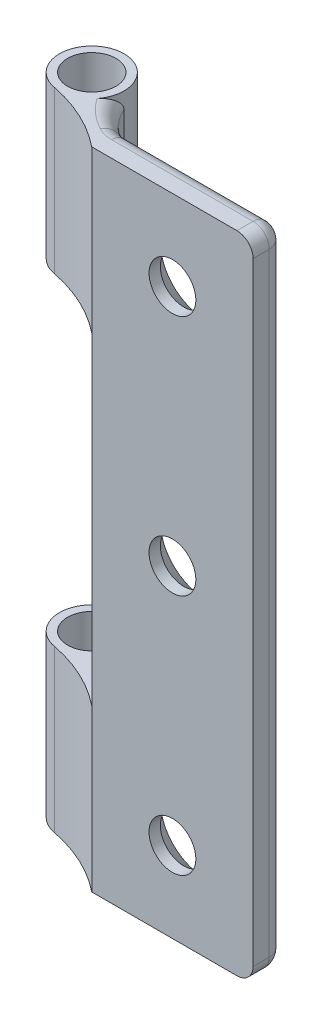
from build123d import *

# Parameters (mm, degrees)
SKETCH3_R                                    = 1.5
BOSS_EXTRUDE2_DEPTH                          = 40
SKETCH4_W                                    = 6
SKETCH4_H                                    = 20
CUT_EXTRUDE1_DEPTH                           = 40
CUT_EXTRUDE1_DEPTH_BACK                      = 200
FILLET1_R                                    = 1
FILLET2_R                                    = 1
CSK_FOR_M2_5_COUNTERSUNK_FLAT_HEAD_S_2_COUNT = 2
CSK_FOR_M2_5_COUNTERSUNK_FLAT_HEAD_S_2_PITCH = 15
CSK_FOR_M2_5_COUNTERSUNK_FLAT_HEAD_S_3_COUNT = 2
CSK_FOR_M2_5_COUNTERSUNK_FLAT_HEAD_S_3_PITCH = 30


with BuildPart() as part:
    # Sketch3 → Boss-Extrude2 (new body)
    with BuildSketch(Plane(origin=(0, 0, 0), x_dir=(1, 0, 0), z_dir=(0, 1, 0))):
        with BuildLine():
            Line((-5, 1), (5, 1))
            Line((5, 1), (5, -1))
            Line((5, -1), (-5, -1))
            ThreePointArc((-5, -1), (-7.043086083, 0.276738431), (-9.332231573, 1.027787491))
            ThreePointArc((-9.332231573, 1.027787491), (-10.291421088, 4.527164553), (-7, 3))
            ThreePointArc((-7, 3), (-6.182675814, 1.817324186), (-5, 1))
        make_face()
        with Locations((-9, 3)):
            Circle(SKETCH3_R, mode=Mode.SUBTRACT)
    extrude(amount=BOSS_EXTRUDE2_DEPTH)

    # Sketch4 → Cut-Extrude1 (cut, two sides)
    with BuildSketch(Plane.XY) as cut_extrude1_sk:
        with Locations((-8, 20)):
            Rectangle(SKETCH4_W, SKETCH4_H)
    extrude(amount=CUT_EXTRUDE1_DEPTH, mode=Mode.SUBTRACT)
    extrude(cut_extrude1_sk.sketch, amount=-CUT_EXTRUDE1_DEPTH_BACK, mode=Mode.SUBTRACT)

    # Fillet1
    fillet1_edges = [part.edges().sort_by_distance(p)[0] for p in [
        (5, 20, -1),
        (-5, 20, -1),
    ]]
    fillet(fillet1_edges, radius=FILLET1_R)

    # Fillet2
    fillet2_edges = [part.edges().sort_by_distance(p)[0] for p in [
        (-6.182675814, 40, -1.817324186),
        (-5, 35, -1),
        (-5, 5, -1),
        (5, 40, 0.5),
        (-0.5, 0, -1),
        (-0.5, 40, -1),
        (4.707106781, 0, -0.707106781),
        (4.707106781, 40, -0.707106781),
        (-6.182675814, 0, -1.817324186),
        (5, 0, 0.5),
    ]]
    fillet(fillet2_edges, radius=FILLET2_R)

    # Sketch6 → CSK for M2.5 Countersunk Flat Head Screw1 (revolve, cut)
    with BuildSketch(Plane(origin=(0, 35, -1), x_dir=(0, 1, 0), z_dir=(1, 0, 0))):
        Polygon((0, 0), (0, 2), (1.45, 2), (1.45, 1.3), (2.75, 0), align=None)
    csk_for_m2_5_countersunk_flat_head_screw = revolve(axis=Axis((0, 35, -7.35), (0, 0, 1)), mode=Mode.SUBTRACT)

    # CSK for M2.5 Countersunk Flat Head S 2: CSK for M2.5 Countersunk Flat Head Screw1 ×2
    with Locations(*[(0, -i * CSK_FOR_M2_5_COUNTERSUNK_FLAT_HEAD_S_2_PITCH, 0) for i in range(1, CSK_FOR_M2_5_COUNTERSUNK_FLAT_HEAD_S_2_COUNT)]):
        add(csk_for_m2_5_countersunk_flat_head_screw, mode=Mode.SUBTRACT)

    # CSK for M2.5 Countersunk Flat Head S 3: CSK for M2.5 Countersunk Flat Head Screw1 ×2
    with Locations(*[(0, -i * CSK_FOR_M2_5_COUNTERSUNK_FLAT_HEAD_S_3_PITCH, 0) for i in range(1, CSK_FOR_M2_5_COUNTERSUNK_FLAT_HEAD_S_3_COUNT)]):
        add(csk_for_m2_5_countersunk_flat_head_screw, mode=Mode.SUBTRACT)


solid = part.part
